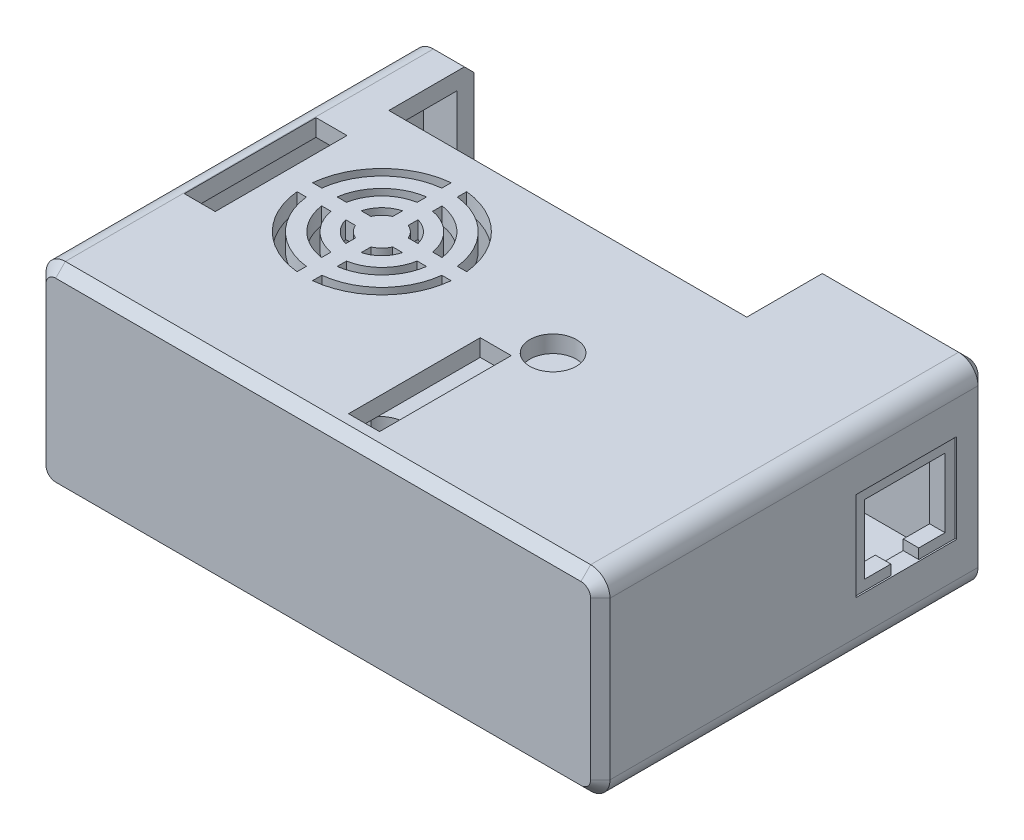
from build123d import *

# Parameters (mm, degrees)
SKETCH1_W           = 92.456
SKETCH1_H           = 63.5
BOSS_EXTRUDE1_DEPTH = 32.131
FILLET1_R           = 3.175
CHAMFER1_SIZE       = 1.5875
SHELL1_T            = 2.794
SKETCH2_W           = 58.674
SKETCH2_H           = 13.97
CUT_EXTRUDE1_DEPTH  = 15.24
SKETCH3_R           = 3.4925
SKETCH3_R_2         = 2.3495
BOSS_EXTRUDE2_DEPTH = 1.143
CUT_EXTRUDE2_DEPTH  = 3.175
SKETCH5_W           = 7.62
SKETCH5_H           = 14.478
CUT_EXTRUDE3_DEPTH  = 7.366
SKETCH6_R           = 3.81
SKETCH6_W           = 5.08
SKETCH6_H           = 21.59
CUT_EXTRUDE4_DEPTH  = 3.175
SKETCH7_W           = 16.51
SKETCH7_H           = 14.605
CUT_EXTRUDE5_DEPTH  = 0.254
CUT_EXTRUDE6_DEPTH  = 12.7


with BuildPart() as part:
    # Sketch1 → Boss-Extrude1 (new body)
    with BuildSketch(Plane(origin=(0, 0, 0), x_dir=(1, 0, 0), z_dir=(0, 1, 0))):
        Rectangle(SKETCH1_W, SKETCH1_H)
    extrude(amount=-BOSS_EXTRUDE1_DEPTH)

    # Fillet1
    fillet1_edges = [part.edges().sort_by_distance(p)[0] for p in [
        (46.228, -32.131, 0),
        (-46.228, -32.131, 0),
        (46.228, 0, 0),
        (-46.228, 0, 0),
    ]]
    fillet(fillet1_edges, radius=FILLET1_R)

    # Chamfer1
    chamfer1_edges = [part.edges().sort_by_distance(p)[0] for p in [
        (0, 0, 31.75),
        (0, 0, -31.75),
        (-46.228, -16.0655, 31.75),
        (0, -32.131, 31.75),
        (46.228, -16.0655, 31.75),
        (45.29806403, -0.92993597, 31.75),
        (45.29806403, -31.20106403, 31.75),
        (-45.29806403, -31.20106403, 31.75),
        (-45.29806403, -0.92993597, 31.75),
        (-46.228, -16.0655, -31.75),
        (46.228, -16.0655, -31.75),
        (0, -32.131, -31.75),
        (45.29806403, -0.92993597, -31.75),
        (45.29806403, -31.20106403, -31.75),
        (-45.29806403, -31.20106403, -31.75),
        (-45.29806403, -0.92993597, -31.75),
    ]]
    chamfer(chamfer1_edges, length=CHAMFER1_SIZE)

    # Shell1 (no face opened: a closed hollow body)
    add(offset(amount=-SHELL1_T, mode=Mode.PRIVATE), mode=Mode.SUBTRACT)

    # Sketch2 → Cut-Extrude1 (cut)
    with BuildSketch(Plane(origin=(0, 0, 0), x_dir=(1, 0, 0), z_dir=(0, 1, 0))):
        with Locations((-8.636, 24.765)):
            Rectangle(SKETCH2_W, SKETCH2_H)
    extrude(amount=-CUT_EXTRUDE1_DEPTH, mode=Mode.SUBTRACT)

    # Sketch3 → Boss-Extrude2 (add)
    with BuildSketch(Plane.XZ.offset(32.131)):
        with Locations((-36.83, 22.86)):
            Circle(SKETCH3_R)
        with Locations((-36.83, 22.86)):
            Circle(SKETCH3_R_2, mode=Mode.SUBTRACT)
        with Locations((36.83, -22.86)):
            Circle(SKETCH3_R)
        with Locations((36.83, -22.86)):
            Circle(SKETCH3_R_2, mode=Mode.SUBTRACT)
        with Locations((36.83, 22.86)):
            Circle(SKETCH3_R)
        with Locations((36.83, 22.86)):
            Circle(SKETCH3_R_2, mode=Mode.SUBTRACT)
        with Locations((-36.83, -22.86)):
            Circle(SKETCH3_R)
        with Locations((-36.83, -22.86)):
            Circle(SKETCH3_R_2, mode=Mode.SUBTRACT)
    extrude(amount=BOSS_EXTRUDE2_DEPTH)

    # Sketch4 → Cut-Extrude2 (cut)
    with BuildSketch(Plane.XZ.offset(32.131)):
        with BuildLine():
            Line((-10.6045, 12.954), (-10.6045, 3.556))
            ThreePointArc((-10.6045, 3.556), (-11.8745, 2.286), (-13.1445, 3.556))
            Line((-13.1445, 3.556), (-13.1445, 12.954))
            ThreePointArc((-13.1445, 12.954), (-11.8745, 14.224), (-10.6045, 12.954))
        make_face()
        with BuildLine():
            Line((-5.8547, 12.954), (-5.8547, 3.556))
            ThreePointArc((-5.8547, 3.556), (-7.1247, 2.286), (-8.3947, 3.556))
            Line((-8.3947, 3.556), (-8.3947, 12.954))
            ThreePointArc((-8.3947, 12.954), (-7.1247, 14.224), (-5.8547, 12.954))
        make_face()
        with BuildLine():
            Line((-1.1049, 12.954), (-1.1049, 3.556))
            ThreePointArc((-1.1049, 3.556), (-2.3749, 2.286), (-3.6449, 3.556))
            Line((-3.6449, 3.556), (-3.6449, 12.954))
            ThreePointArc((-3.6449, 12.954), (-2.3749, 14.224), (-1.1049, 12.954))
        make_face()
        with BuildLine():
            Line((3.6449, 12.954), (3.6449, 3.556))
            ThreePointArc((3.6449, 3.556), (2.3749, 2.286), (1.1049, 3.556))
            Line((1.1049, 3.556), (1.1049, 12.954))
            ThreePointArc((1.1049, 12.954), (2.3749, 14.224), (3.6449, 12.954))
        make_face()
        with BuildLine():
            Line((8.3947, 12.954), (8.3947, 3.556))
            ThreePointArc((8.3947, 3.556), (7.1247, 2.286), (5.8547, 3.556))
            Line((5.8547, 3.556), (5.8547, 12.954))
            ThreePointArc((5.8547, 12.954), (7.1247, 14.224), (8.3947, 12.954))
        make_face()
        with BuildLine():
            Line((13.1445, 12.954), (13.1445, 3.556))
            ThreePointArc((13.1445, 3.556), (11.8745, 2.286), (10.6045, 3.556))
            Line((10.6045, 3.556), (10.6045, 12.954))
            ThreePointArc((10.6045, 12.954), (11.8745, 14.224), (13.1445, 12.954))
        make_face()
        with BuildLine():
            Line((-10.6045, -12.954), (-10.6045, -3.556))
            ThreePointArc((-10.6045, -3.556), (-11.8745, -2.286), (-13.1445, -3.556))
            Line((-13.1445, -3.556), (-13.1445, -12.954))
            ThreePointArc((-13.1445, -12.954), (-11.8745, -14.224), (-10.6045, -12.954))
        make_face()
        with BuildLine():
            Line((-5.8547, -12.954), (-5.8547, -3.556))
            ThreePointArc((-5.8547, -3.556), (-7.1247, -2.286), (-8.3947, -3.556))
            Line((-8.3947, -3.556), (-8.3947, -12.954))
            ThreePointArc((-8.3947, -12.954), (-7.1247, -14.224), (-5.8547, -12.954))
        make_face()
        with BuildLine():
            Line((-1.1049, -12.954), (-1.1049, -3.556))
            ThreePointArc((-1.1049, -3.556), (-2.3749, -2.286), (-3.6449, -3.556))
            Line((-3.6449, -3.556), (-3.6449, -12.954))
            ThreePointArc((-3.6449, -12.954), (-2.3749, -14.224), (-1.1049, -12.954))
        make_face()
        with BuildLine():
            Line((3.6449, -12.954), (3.6449, -3.556))
            ThreePointArc((3.6449, -3.556), (2.3749, -2.286), (1.1049, -3.556))
            Line((1.1049, -3.556), (1.1049, -12.954))
            ThreePointArc((1.1049, -12.954), (2.3749, -14.224), (3.6449, -12.954))
        make_face()
        with BuildLine():
            Line((8.3947, -12.954), (8.3947, -3.556))
            ThreePointArc((8.3947, -3.556), (7.1247, -2.286), (5.8547, -3.556))
            Line((5.8547, -3.556), (5.8547, -12.954))
            ThreePointArc((5.8547, -12.954), (7.1247, -14.224), (8.3947, -12.954))
        make_face()
        with BuildLine():
            Line((13.1445, -12.954), (13.1445, -3.556))
            ThreePointArc((13.1445, -3.556), (11.8745, -2.286), (10.6045, -3.556))
            Line((10.6045, -3.556), (10.6045, -12.954))
            ThreePointArc((10.6045, -12.954), (11.8745, -14.224), (13.1445, -12.954))
        make_face()
        with BuildLine():
            Line((16.383, 2.159), (18.199191698, 2.159))
            ThreePointArc((18.199191698, 2.159), (21.717, 4.1275), (25.234808302, 2.159))
            Line((25.234808302, 2.159), (27.051, 2.159))
            ThreePointArc((27.051, 2.159), (29.21, 0), (27.051, -2.159))
            Line((27.051, -2.159), (25.234808302, -2.159))
            ThreePointArc((25.234808302, -2.159), (21.717, -4.1275), (18.199191698, -2.159))
            Line((18.199191698, -2.159), (16.383, -2.159))
            ThreePointArc((16.383, -2.159), (14.224, 0), (16.383, 2.159))
        make_face()
        with BuildLine():
            Line((-16.383, 2.159), (-18.199191698, 2.159))
            ThreePointArc((-18.199191698, 2.159), (-21.717, 4.1275), (-25.234808302, 2.159))
            Line((-25.234808302, 2.159), (-27.051, 2.159))
            ThreePointArc((-27.051, 2.159), (-29.21, 0), (-27.051, -2.159))
            Line((-27.051, -2.159), (-25.234808302, -2.159))
            ThreePointArc((-25.234808302, -2.159), (-21.717, -4.1275), (-18.199191698, -2.159))
            Line((-18.199191698, -2.159), (-16.383, -2.159))
            ThreePointArc((-16.383, -2.159), (-14.224, 0), (-16.383, 2.159))
        make_face()
    extrude(amount=-CUT_EXTRUDE2_DEPTH, mode=Mode.SUBTRACT)

    # Sketch5 → Cut-Extrude3 (cut)
    with BuildSketch(Plane.XZ.offset(32.131)):
        with Locations((-42.418, 0)):
            Rectangle(SKETCH5_W, SKETCH5_H)
    extrude(amount=-CUT_EXTRUDE3_DEPTH, mode=Mode.SUBTRACT)

    # Sketch6 → Cut-Extrude4 (cut)
    with BuildSketch(Plane(origin=(0, 0, 0), x_dir=(1, 0, 0), z_dir=(0, 1, 0))):
        with Locations((9.906, -3.175)):
            Circle(SKETCH6_R)
        with Locations((-40.386, 0)):
            Rectangle(SKETCH6_W, SKETCH6_H)
        with Locations((4.318, -17.78)):
            Rectangle(SKETCH6_W, SKETCH6_H)
        with BuildLine():
            Line((-22.606, 11.103606441), (-22.606, 12.636340451))
            ThreePointArc((-22.606, 12.636340451), (-30.316256121, 8.980256121), (-33.972340451, 1.27))
            Line((-33.972340451, 1.27), (-32.439606441, 1.27))
            ThreePointArc((-32.439606441, 1.27), (-29.238625387, 7.902625387), (-22.606, 11.103606441))
        make_face()
        with BuildLine():
            Line((-20.066, -12.636340451), (-20.066, -11.103606441))
            ThreePointArc((-20.066, -11.103606441), (-13.433374613, -7.902625387), (-10.232393559, -1.27))
            Line((-10.232393559, -1.27), (-8.699659549, -1.27))
            ThreePointArc((-8.699659549, -1.27), (-12.355743879, -8.980256121), (-20.066, -12.636340451))
        make_face()
        with BuildLine():
            Line((-22.606, -12.636340451), (-22.606, -11.103606441))
            ThreePointArc((-22.606, -11.103606441), (-29.238625387, -7.902625387), (-32.439606441, -1.27))
            Line((-32.439606441, -1.27), (-33.972340451, -1.27))
            ThreePointArc((-33.972340451, -1.27), (-30.316256121, -8.980256121), (-22.606, -12.636340451))
        make_face()
        with BuildLine():
            Line((-22.606, 3.048), (-22.606, 4.655896906))
            ThreePointArc((-22.606, 4.655896906), (-24.748497326, 3.412497326), (-25.991896906, 1.27))
            Line((-25.991896906, 1.27), (-24.384, 1.27))
            ThreePointArc((-24.384, 1.27), (-23.670866591, 2.334866591), (-22.606, 3.048))
        make_face()
        with BuildLine():
            Line((-20.066, 3.048), (-20.066, 4.655896906))
            ThreePointArc((-20.066, 4.655896906), (-17.923502674, 3.412497326), (-16.680103094, 1.27))
            Line((-16.680103094, 1.27), (-18.288, 1.27))
            ThreePointArc((-18.288, 1.27), (-19.001133409, 2.334866591), (-20.066, 3.048))
        make_face()
        with BuildLine():
            Line((-20.066, 11.103606441), (-20.066, 12.636340451))
            ThreePointArc((-20.066, 12.636340451), (-12.355743879, 8.980256121), (-8.699659549, 1.27))
            Line((-8.699659549, 1.27), (-10.232393559, 1.27))
            ThreePointArc((-10.232393559, 1.27), (-13.433374613, 7.902625387), (-20.066, 11.103606441))
        make_face()
        with BuildLine():
            Line((-20.066, 7.062216384), (-20.066, 8.606300033))
            ThreePointArc((-20.066, 8.606300033), (-15.184524557, 6.151475443), (-12.729699967, 1.27))
            Line((-12.729699967, 1.27), (-14.273783616, 1.27))
            ThreePointArc((-14.273783616, 1.27), (-16.262155292, 5.073844708), (-20.066, 7.062216384))
        make_face()
        with BuildLine():
            Line((-18.288, -1.27), (-16.680103094, -1.27))
            ThreePointArc((-16.680103094, -1.27), (-17.923502674, -3.412497326), (-20.066, -4.655896906))
            Line((-20.066, -4.655896906), (-20.066, -3.048))
            ThreePointArc((-20.066, -3.048), (-19.001133409, -2.334866591), (-18.288, -1.27))
        make_face()
        with BuildLine():
            Line((-22.606, 7.062216384), (-22.606, 8.606300033))
            ThreePointArc((-22.606, 8.606300033), (-27.487475443, 6.151475443), (-29.942300033, 1.27))
            Line((-29.942300033, 1.27), (-28.398216384, 1.27))
            ThreePointArc((-28.398216384, 1.27), (-26.409844708, 5.073844708), (-22.606, 7.062216384))
        make_face()
        with BuildLine():
            Line((-14.273783616, -1.27), (-12.729699967, -1.27))
            ThreePointArc((-12.729699967, -1.27), (-15.184524557, -6.151475443), (-20.066, -8.606300033))
            Line((-20.066, -8.606300033), (-20.066, -7.062216384))
            ThreePointArc((-20.066, -7.062216384), (-16.262155292, -5.073844708), (-14.273783616, -1.27))
        make_face()
        with BuildLine():
            Line((-25.991896906, -1.27), (-24.384, -1.27))
            ThreePointArc((-24.384, -1.27), (-23.670866591, -2.334866591), (-22.606, -3.048))
            Line((-22.606, -3.048), (-22.606, -4.655896906))
            ThreePointArc((-22.606, -4.655896906), (-24.748497326, -3.412497326), (-25.991896906, -1.27))
        make_face()
        with BuildLine():
            Line((-29.942300033, -1.27), (-28.398216384, -1.27))
            ThreePointArc((-28.398216384, -1.27), (-26.409844708, -5.073844708), (-22.606, -7.062216384))
            Line((-22.606, -7.062216384), (-22.606, -8.606300033))
            ThreePointArc((-22.606, -8.606300033), (-27.487475443, -6.151475443), (-29.942300033, -1.27))
        make_face()
    extrude(amount=-CUT_EXTRUDE4_DEPTH, mode=Mode.SUBTRACT)

    # Sketch7 → Cut-Extrude5 (cut)
    with BuildSketch(Plane(origin=(46.228, 0, 0), x_dir=(0, 0, -1), z_dir=(1, 0, 0))):
        with Locations((18.415, -15.9385)):
            Rectangle(SKETCH7_W, SKETCH7_H)
    extrude(amount=-CUT_EXTRUDE5_DEPTH, mode=Mode.SUBTRACT)

    # Sketch8 → Cut-Extrude6 (cut)
    with BuildSketch(Plane(origin=(45.974, 0, 0), x_dir=(0, 0, -1), z_dir=(1, 0, 0))):
        Polygon((11.811, -10.287), (25.019, -10.287), (25.019, -21.59), (20.701, -21.59), (20.701, -23.241), (16.129, -23.241), (16.129, -21.59), (11.811, -21.59), align=None)
    extrude(amount=-CUT_EXTRUDE6_DEPTH, mode=Mode.SUBTRACT)


solid = part.part
